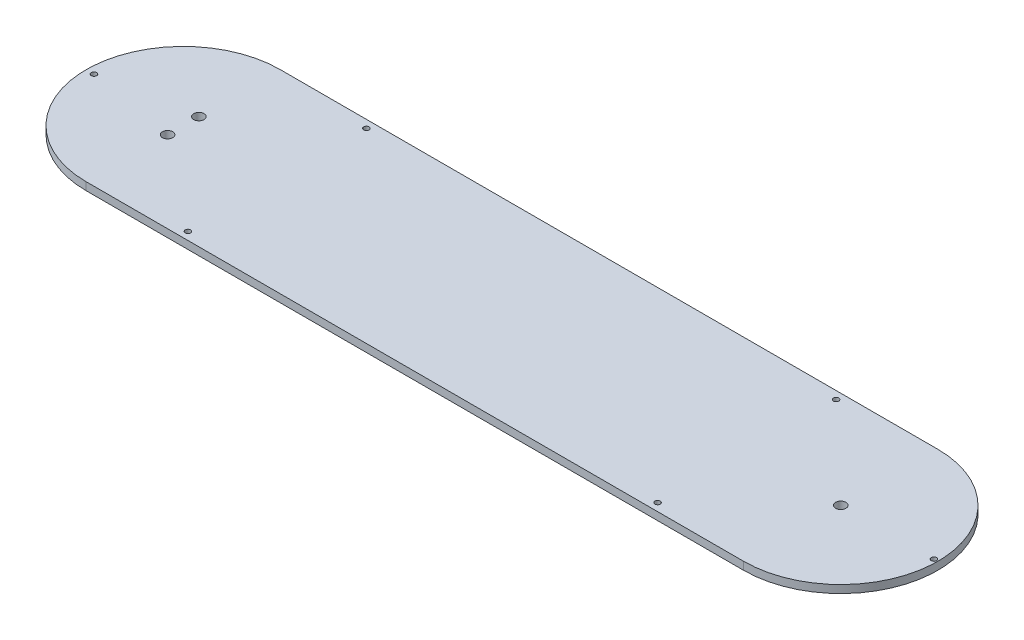
from build123d import *

# Parameters (mm, degrees)
SKETCH1_R           = 1.0922
SKETCH1_R_2         = 2.1
BOSS_EXTRUDE1_DEPTH = 3.175


with BuildPart() as part:
    # Sketch1 → Boss-Extrude1 (new body)
    with BuildSketch(Plane(origin=(0, 0, 0), x_dir=(1, 0, 0), z_dir=(0, 1, 0))):
        with BuildLine():
            Line((0, 39.37), (266.7, 39.37))
            ThreePointArc((266.7, 39.37), (306.07, 0), (266.7, -39.37))
            Line((266.7, -39.37), (0, -39.37))
            ThreePointArc((0, -39.37), (-39.37, 0), (0, 39.37))
        make_face()
        with Locations((38.1, 36.195)):
            Circle(SKETCH1_R, mode=Mode.SUBTRACT)
        with Locations((228.6, 36.195)):
            Circle(SKETCH1_R, mode=Mode.SUBTRACT)
        with Locations((38.1, -36.195)):
            Circle(SKETCH1_R, mode=Mode.SUBTRACT)
        with Locations((228.6, -36.195)):
            Circle(SKETCH1_R, mode=Mode.SUBTRACT)
        with Locations((-36.195, 0)):
            Circle(SKETCH1_R, mode=Mode.SUBTRACT)
        with Locations((304.4825, 0)):
            Circle(SKETCH1_R, mode=Mode.SUBTRACT)
        with Locations((266.7, 0)):
            Circle(SKETCH1_R_2, mode=Mode.SUBTRACT)
        with Locations((0, -6.35)):
            Circle(SKETCH1_R_2, mode=Mode.SUBTRACT)
        with Locations((0, 6.35)):
            Circle(SKETCH1_R_2, mode=Mode.SUBTRACT)
    extrude(amount=BOSS_EXTRUDE1_DEPTH)


solid = part.part
